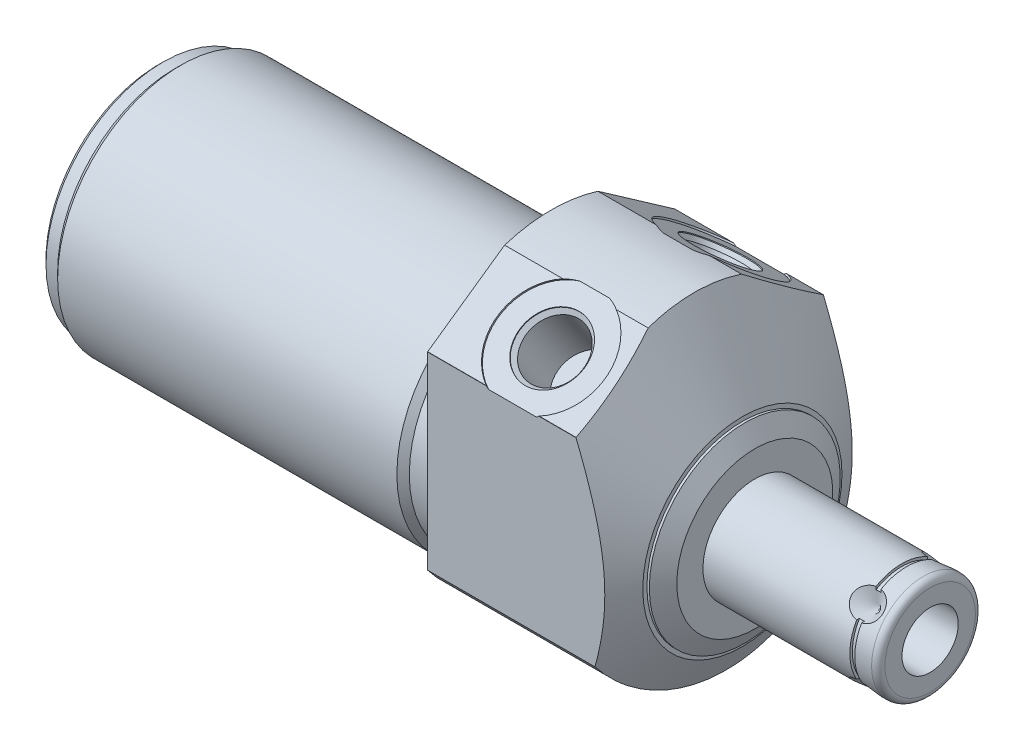
from build123d import *

# Parameters (mm, degrees)
SKETCH1_R           = 25.4
EXTRUDE1_DEPTH      = 31.1404
EXTRUDE1_DEPTH_BACK = 60.1472
CUT_EXTRUDE1_REACH  = 62.147
SKETCH2_R           = 25.4
SKETCH2_R_2         = 18.8595
CUT_EXTRUDE3_REACH  = 93.288
SKETCH4_R           = 25.4
CHAMFER1_SIZE       = 0.762
CIRPATTERN1_COUNT   = 4
SKETCH21_W          = 0.762
SKETCH21_H          = 0.381


with BuildPart() as part:
    # Sketch1 → Extrude1 (new body, two sides)
    with BuildSketch(Plane(origin=(0, 0, 0), x_dir=(0, 0, -1), z_dir=(1, 0, 0))) as extrude1_sk:
        Circle(SKETCH1_R)
    extrude(amount=EXTRUDE1_DEPTH)
    extrude(extrude1_sk.sketch, amount=-EXTRUDE1_DEPTH_BACK)

    # Sketch2 → Cut-Extrude1 (cut, up to next)
    with BuildSketch(Plane(origin=(0, 0, 0), x_dir=(0, 0, -1), z_dir=(1, 0, 0)), mode=Mode.PRIVATE) as cut_extrude1_sk1:
        Circle(SKETCH2_R)
        with Locations((0, -4.191)):
            Circle(SKETCH2_R_2, mode=Mode.SUBTRACT)
    cut_extrude1_tool1 = extrude(cut_extrude1_sk1.sketch, amount=-CUT_EXTRUDE1_REACH, mode=Mode.PRIVATE) & part.part
    add(cut_extrude1_tool1.solids().sort_by_distance((0, 0, 24.68158))[0], mode=Mode.SUBTRACT)

    # Sketch4 → Cut-Extrude3 (cut, up to next)
    with BuildSketch(Plane.ZY.offset(-31.1404), mode=Mode.PRIVATE) as cut_extrude3_sk1:
        Circle(SKETCH4_R)
        with BuildLine():
            Line((18.923, -14.455283714), (18.923, 14.455283714))
            ThreePointArc((18.923, 14.455283714), (18.914286675, 14.466682959), (18.905566483, 14.478076951))
            Line((18.905566483, 14.478076951), (7.138857516, 22.71721527))
            ThreePointArc((7.138857516, 22.71721527), (0, 23.8125), (-7.138857516, 22.71721527))
            Line((-7.138857516, 22.71721527), (-18.905566483, 14.478076951))
            ThreePointArc((-18.905566483, 14.478076951), (-18.914286675, 14.466682959), (-18.923, 14.455283714))
            Line((-18.923, 14.455283714), (-18.923, -14.455283714))
            ThreePointArc((-18.923, -14.455283714), (0, -23.8125), (18.923, -14.455283714))
        make_face(mode=Mode.SUBTRACT)
    cut_extrude3_tool1 = extrude(cut_extrude3_sk1.sketch, amount=CUT_EXTRUDE3_REACH, mode=Mode.PRIVATE) & part.part
    add(cut_extrude3_tool1.solids().sort_by_distance((31.1404, 0, -24.68158))[0], mode=Mode.SUBTRACT)

    # Sketch6 → Cut-Revolve2 (revolve, cut)
    with BuildSketch(Plane.XY, mode=Mode.PRIVATE) as cut_revolve2_sk:
        Polygon((16.382172419, 33.309), (29.2354, 11.046556788), (29.2354, 10.414), (29.600606832, 10.414), (31.1404, 7.747), (31.1404, 33.309), align=None)
    revolve(cut_revolve2_sk.sketch.rotate(Axis((1.987224567, -4.191, 0), (1, 0, 0)), 90), axis=Axis((1.987224567, -4.191, 0), (1, 0, 0)), mode=Mode.SUBTRACT)  # turned: the seam where the file's is

    # S2D0002 → Cut-Revolve3 (revolve, cut)
    with BuildSketch(Plane(origin=(13.0048, 13.712414668, 8.609072086), x_dir=(0, 0.422618262, -0.906307787), z_dir=(1, 0, 0))):
        Polygon((3.058321962, 6.915149075), (6.247621871, 7.477508699), (6.203515233, 7.727649868), (-1.926072768, 6.294184161), (-0.250020557, -3.211180271), (4.102435788, -2.443724785), (2.59619413, 6.098596146), (3.080375281, 6.790078491), align=None)
    cut_revolve3 = revolve(axis=Axis((13.0048, 2.978510308, 2.074416081), (0, 0.819152044, 0.573576436)), mode=Mode.SUBTRACT)

    # Mirror1: Cut-Revolve3 across plane
    add(cut_revolve3.mirror(Plane.XY), mode=Mode.SUBTRACT)

    # Sketch10 → Cut-Revolve6 (revolve, cut)
    with BuildSketch(Plane.XY, mode=Mode.PRIVATE) as cut_revolve6_sk:
        Polygon((0, 14.6685), (0, 13.716), (-3.81, 13.716), (-4.7625, 14.6685), align=None)
    revolve(cut_revolve6_sk.sketch.rotate(Axis((-5.09397, -4.191, 0), (1, 0, 0)), 90), axis=Axis((-5.09397, -4.191, 0), (1, 0, 0)), mode=Mode.SUBTRACT)  # turned: the seam where the file's is

    # Sketch12 → Cut-Revolve8 (revolve, cut)
    with BuildSketch(Plane.XY, mode=Mode.PRIVATE) as cut_revolve8_sk:
        Polygon((-60.1472, 14.6685), (-60.1472, 13.716), (-57.6072, 13.716), (-56.6547, 14.6685), align=None)
    revolve(cut_revolve8_sk.sketch.rotate(Axis((-50.92827, -4.191, 0), (1, 0, 0)), 90), axis=Axis((-50.92827, -4.191, 0), (1, 0, 0)), mode=Mode.SUBTRACT)  # turned: the seam where the file's is

    # Chamfer1
    chamfer1_edges = [part.edges().sort_by_distance(p)[0] for p in [
        (-60.1472, -4.191, -17.907),
    ]]
    chamfer(chamfer1_edges, length=CHAMFER1_SIZE)

    # Sketch13 → Revolve1 (revolve)
    with BuildSketch(Plane.XY, mode=Mode.PRIVATE) as revolve1_sk:
        with BuildLine():
            Line((31.1404, -4.191), (57.95, -4.191))
            Line((57.95, -4.191), (57.95, -11.1125))
            ThreePointArc((57.95, -11.1125), (57.65242049, -11.83092049), (56.934, -12.1285))
            Line((56.934, -12.1285), (31.1404, -12.1285))
            Line((31.1404, -12.1285), (31.1404, -4.191))
        make_face()
    revolve(revolve1_sk.sketch.rotate(Axis((4.7498, -4.191, 0), (1, 0, 0)), 270), axis=Axis((4.7498, -4.191, 0), (1, 0, 0)))  # turned: the seam where the file's is

    # S2D0001 → Cut-Revolve9 (revolve, cut)
    with BuildSketch(Plane.XY, mode=Mode.PRIVATE) as cut_revolve9_sk:
        Polygon((57.95, 0.1143), (42.71, 0.1143), (40.123114777, -4.191), (57.95, -4.191), align=None)
    revolve(cut_revolve9_sk.sketch.rotate(Axis((-2.8067, -4.191, 0), (-1, 0, 0)), 270), axis=Axis((-2.8067, -4.191, 0), (-1, 0, 0)), mode=Mode.SUBTRACT)  # turned: the seam where the file's is

    # Sketch16 → Cut-Revolve10 (revolve, cut)
    with BuildSketch(Plane(origin=(0, -7.15448452, 2.96348452), x_dir=(1, 0, 0), z_dir=(0, -0.707106781, -0.707106781)), mode=Mode.PRIVATE) as cut_revolve10_sk:
        Polygon((53.9876, -12.1285), (51.5746, -12.1285), (53.9876, -9.7155), align=None)
    cut_revolve10 = revolve(cut_revolve10_sk.sketch.rotate(Axis((53.9876, -4.694604004, 0.503604004), (0, -0.707106781, 0.707106781)), 270), axis=Axis((53.9876, -4.694604004, 0.503604004), (0, -0.707106781, 0.707106781)), mode=Mode.SUBTRACT)  # turned: the seam where the file's is

    # CirPattern1: Cut-Revolve10 ×4 about axis
    cirpattern1_axis = Axis((4.7498, -4.191, 0), (-1, 0, 0))
    for i in range(1, CIRPATTERN1_COUNT):
        add(cut_revolve10.rotate(cirpattern1_axis, i * 360 / CIRPATTERN1_COUNT), mode=Mode.SUBTRACT)

    # Sketch21 → Cut-Revolve11 (revolve, cut)
    with BuildSketch(Plane.XY, mode=Mode.PRIVATE) as cut_revolve11_sk:
        with Locations((53.9876, 3.556)):
            Rectangle(SKETCH21_W, SKETCH21_H)
    revolve(cut_revolve11_sk.sketch.rotate(Axis((23.873488058, -4.191, 0), (1, 0, 0)), 90), axis=Axis((23.873488058, -4.191, 0), (1, 0, 0)), mode=Mode.SUBTRACT)  # turned: the seam where the file's is


solid = part.part
